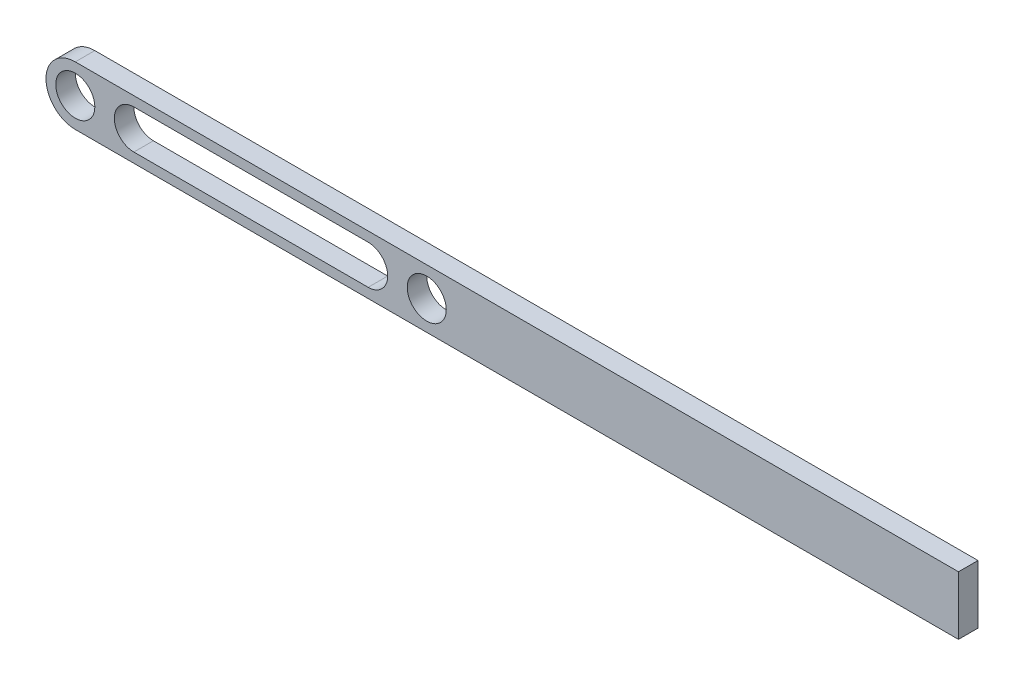
from build123d import *

# Parameters (mm, degrees)
SKETCH1_R           = 10
BOSS_EXTRUDE1_DEPTH = 10


with BuildPart() as part:
    # Sketch1 → Boss-Extrude1 (new body)
    with BuildSketch(Plane.XY):
        with BuildLine():
            Line((0, 15), (180, 15))
            Line((180, 15), (452.334951872, 15))
            Line((452.334951872, 15), (452.334951872, -15))
            Line((452.334951872, -15), (180, -15))
            Line((180, -15), (0, -15))
            ThreePointArc((0, -15), (-15, 0), (0, 15))
        make_face()
        Circle(SKETCH1_R, mode=Mode.SUBTRACT)
        with Locations((180, 0)):
            Circle(SKETCH1_R, mode=Mode.SUBTRACT)
        with BuildLine():
            Line((30, 10), (150, 10))
            ThreePointArc((150, 10), (160, 0), (150, -10))
            Line((150, -10), (30, -10))
            ThreePointArc((30, -10), (20, 0), (30, 10))
        make_face(mode=Mode.SUBTRACT)
    extrude(amount=BOSS_EXTRUDE1_DEPTH)


solid = part.part
